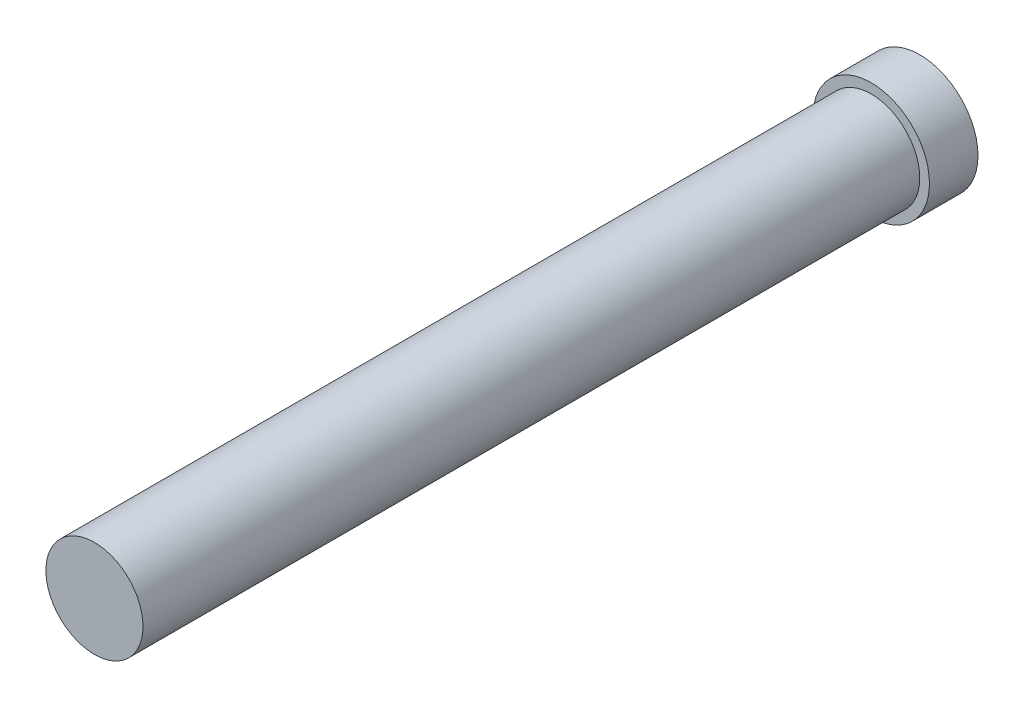
from build123d import *

# Parameters (mm, degrees)
SKETCH1_R           = 7.62
BOSS_EXTRUDE1_DEPTH = 6.35
SKETCH2_R           = 6.35
BOSS_EXTRUDE2_DEPTH = 101.6


with BuildPart() as part:
    # Sketch1 → Boss-Extrude1 (new body)
    with BuildSketch(Plane.XY):
        Circle(SKETCH1_R)
    extrude(amount=BOSS_EXTRUDE1_DEPTH)

    # Sketch2 → Boss-Extrude2 (add)
    with BuildSketch(Plane.XY.offset(6.35)):
        Circle(SKETCH2_R)
    extrude(amount=BOSS_EXTRUDE2_DEPTH)


solid = part.part
